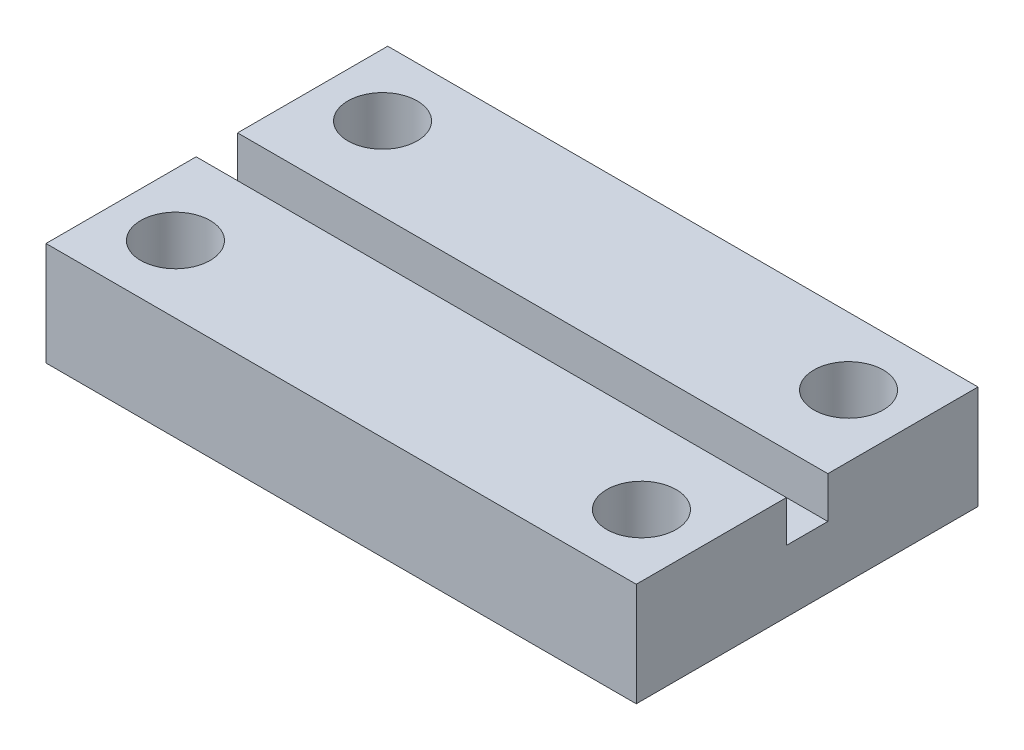
from build123d import *

# Parameters (mm, degrees)
SKETCH1_W           = 57
SKETCH1_H           = 33
BOSS_EXTRUDE1_DEPTH = 10
SKETCH3_R           = 3.35
CUT_EXTRUDE1_DEPTH  = 11
SKETCH4_R           = 3.35
CUT_EXTRUDE2_DEPTH  = 11
SKETCH10_R          = 3.35
CUT_EXTRUDE5_DEPTH  = 11
SKETCH12_R          = 3.35
CUT_EXTRUDE6_DEPTH  = 11
SKETCH16_W          = 57
SKETCH16_H          = 4
CUT_EXTRUDE7_DEPTH  = 4


with BuildPart() as part:
    # Sketch1 → Boss-Extrude1 (new body)
    with BuildSketch(Plane(origin=(0, 0, 0), x_dir=(1, 0, 0), z_dir=(0, 1, 0))):
        with Locations((28.5, 16.5)):
            Rectangle(SKETCH1_W, SKETCH1_H)
    extrude(amount=BOSS_EXTRUDE1_DEPTH)

    # Sketch3 → Cut-Extrude1 (cut, through all)
    with BuildSketch(Plane.XZ):
        with Locations((6, -6.5)):
            Circle(SKETCH3_R)
    extrude(amount=-CUT_EXTRUDE1_DEPTH, mode=Mode.SUBTRACT)

    # Sketch4 → Cut-Extrude2 (cut, through all)
    with BuildSketch(Plane.XZ):
        with Locations((51, -26.5)):
            Circle(SKETCH4_R)
    extrude(amount=-CUT_EXTRUDE2_DEPTH, mode=Mode.SUBTRACT)

    # Sketch10 → Cut-Extrude5 (cut, through all)
    with BuildSketch(Plane.XZ):
        with Locations((6, -26.5)):
            Circle(SKETCH10_R)
    extrude(amount=-CUT_EXTRUDE5_DEPTH, mode=Mode.SUBTRACT)

    # Sketch12 → Cut-Extrude6 (cut, through all)
    with BuildSketch(Plane.XZ):
        with Locations((51, -6.5)):
            Circle(SKETCH12_R)
    extrude(amount=-CUT_EXTRUDE6_DEPTH, mode=Mode.SUBTRACT)

    # Sketch16 → Cut-Extrude7 (cut)
    with BuildSketch(Plane(origin=(0, 10, 0), x_dir=(1, 0, 0), z_dir=(0, 1, 0))):
        with Locations((28.5, 16.5)):
            Rectangle(SKETCH16_W, SKETCH16_H)
    extrude(amount=-CUT_EXTRUDE7_DEPTH, mode=Mode.SUBTRACT)


solid = part.part
